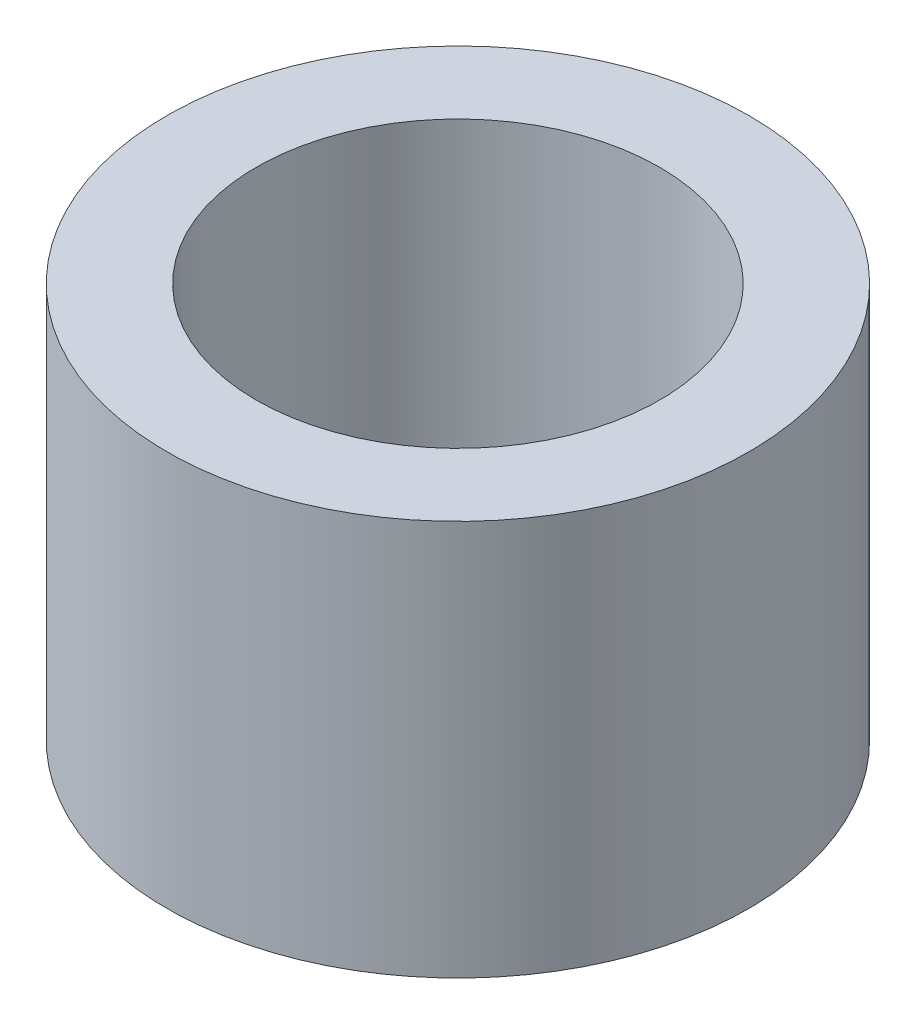
from build123d import *

# Parameters (mm, degrees)
SKETCH1_W = 8.6106
SKETCH1_H = 38.1


with BuildPart() as part:
    # Sketch1 → Revolve1 (revolve)
    with BuildSketch(Plane.XY):
        with Locations((-23.7363, 19.05)):
            Rectangle(SKETCH1_W, SKETCH1_H)
    revolve(axis=Axis((0, 0, 0), (0, 1, 0)))


solid = part.part
